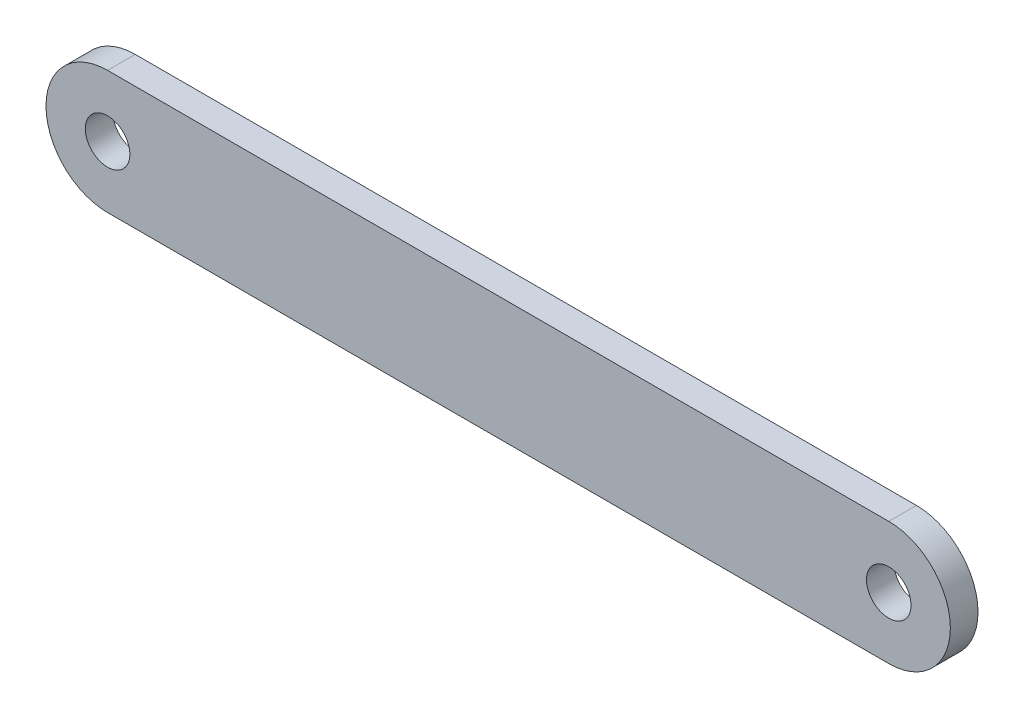
from build123d import *

# Parameters (mm, degrees)
CROQUIS1_R              = 1.7
SALIENTE_EXTRUIR1_DEPTH = 2.11


with BuildPart() as part:
    # Croquis1 → Saliente-Extruir1 (new body)
    with BuildSketch(Plane.XY):
        with BuildLine():
            Line((0, 4.7), (59.61, 4.7))
            ThreePointArc((59.61, 4.7), (64.31, 0), (59.61, -4.7))
            Line((59.61, -4.7), (0, -4.7))
            ThreePointArc((0, -4.7), (-4.7, 0), (0, 4.7))
        make_face()
        Circle(CROQUIS1_R, mode=Mode.SUBTRACT)
        with Locations((59.61, 0)):
            Circle(CROQUIS1_R, mode=Mode.SUBTRACT)
    extrude(amount=SALIENTE_EXTRUIR1_DEPTH)


solid = part.part
